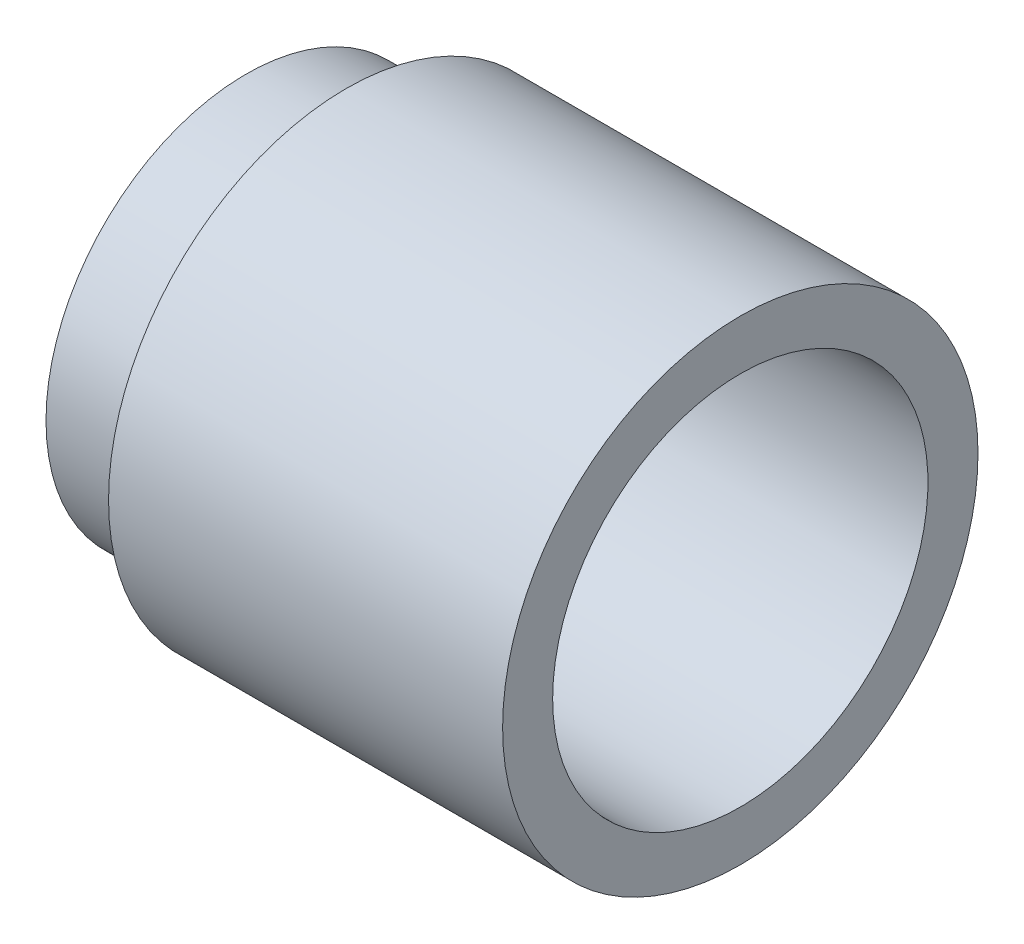
from build123d import *


with BuildPart() as part:
    # Esquisse1 → Révolution1 (revolve)
    with BuildSketch(Plane.XY, mode=Mode.PRIVATE) as r_volution1_sk:
        Polygon((0, 8), (0, 7.5), (19.75, 7.5), (19.75, 9.5), (4, 9.5), (4, 8), align=None)
    revolve(r_volution1_sk.sketch.rotate(Axis((0, 0, 0), (1, 0, 0)), 90), axis=Axis((0, 0, 0), (1, 0, 0)))  # turned: the seam where the file's is


solid = part.part
